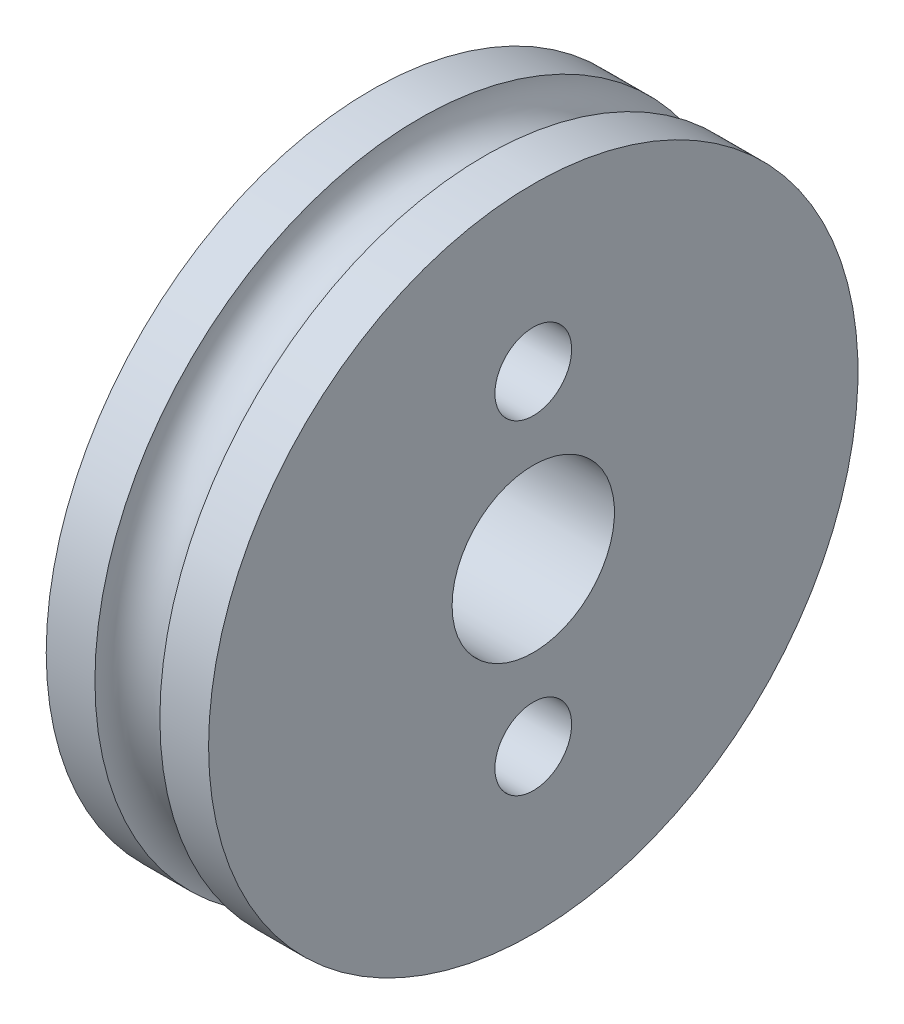
from build123d import *

# Parameters (mm, degrees)
F_3_0MM_DOWEL_HOLE1_D           = 3
F_3_0MM_DOWEL_HOLE1_CSINK_D     = 3.05
F_3_0MM_DOWEL_HOLE1_CSINK_ANGLE = 90


with BuildPart() as part:
    # Sketch1 → Revolve1 (revolve)
    with BuildSketch(Plane.XY):
        with BuildLine():
            Line((0, 3.175), (6.35, 3.175))
            Line((6.35, 3.175), (6.35, 12.7))
            Line((6.35, 12.7), (4.445, 12.7))
            ThreePointArc((4.445, 12.7), (3.175, 11.43), (1.905, 12.7))
            Line((1.905, 12.7), (0, 12.7))
            Line((0, 12.7), (0, 3.175))
        make_face()
    revolve(axis=Axis((0, 0, 0), (1, 0, 0)))

    # Ø3.0mm Dowel Hole1 (through all)
    with Locations(Plane.ZY):
        with Locations((0, 6.35), (0, -6.35)):
            CounterSinkHole(F_3_0MM_DOWEL_HOLE1_D / 2, F_3_0MM_DOWEL_HOLE1_CSINK_D / 2, counter_sink_angle=F_3_0MM_DOWEL_HOLE1_CSINK_ANGLE)


solid = part.part
